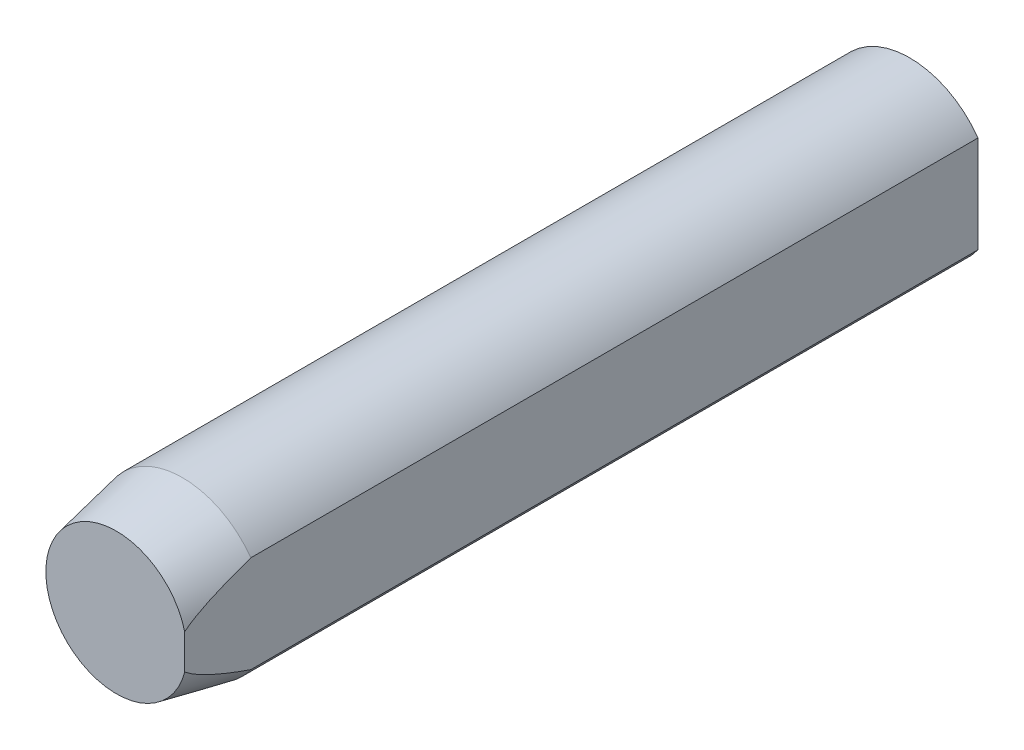
from build123d import *

# Parameters (mm, degrees)
SKETCH_1_R          = 1.9
EXTRUDE_1_DEPTH     = 18
CHAMFER_1_SIZE      = 1.5
CHAMFER_1_SIZE2     = 0.3
SKETCH_2_W          = 0.7
SKETCH_2_H          = 3.336204296
CUT_EXTRUDE_1_DEPTH = 18


with BuildPart() as part:
    # 草图1 → 凸台-拉伸1 (new body)
    with BuildSketch(Plane.XY):
        Circle(SKETCH_1_R)
    extrude(amount=EXTRUDE_1_DEPTH)

    # 倒角1
    chamfer_1_edges = [part.edges().sort_by_distance(p)[0] for p in [
        (-1.9, 0, 18),
    ]]
    chamfer_1_side = [part.faces().sort_by_distance(p)[0] for p in [
        (-1.9, 0, 9),
    ]]
    chamfer(chamfer_1_edges, length=CHAMFER_1_SIZE, length2=CHAMFER_1_SIZE2, reference=chamfer_1_side[0])

    # 草图2 → 切除-拉伸1 (cut)
    with BuildSketch(Plane(origin=(0, 0, 0), x_dir=(-1, 0, 0), z_dir=(0, 0, -1))):
        with Locations((-1.9, 0)):
            Rectangle(SKETCH_2_W, SKETCH_2_H)
    extrude(amount=-CUT_EXTRUDE_1_DEPTH, mode=Mode.SUBTRACT)


solid = part.part
